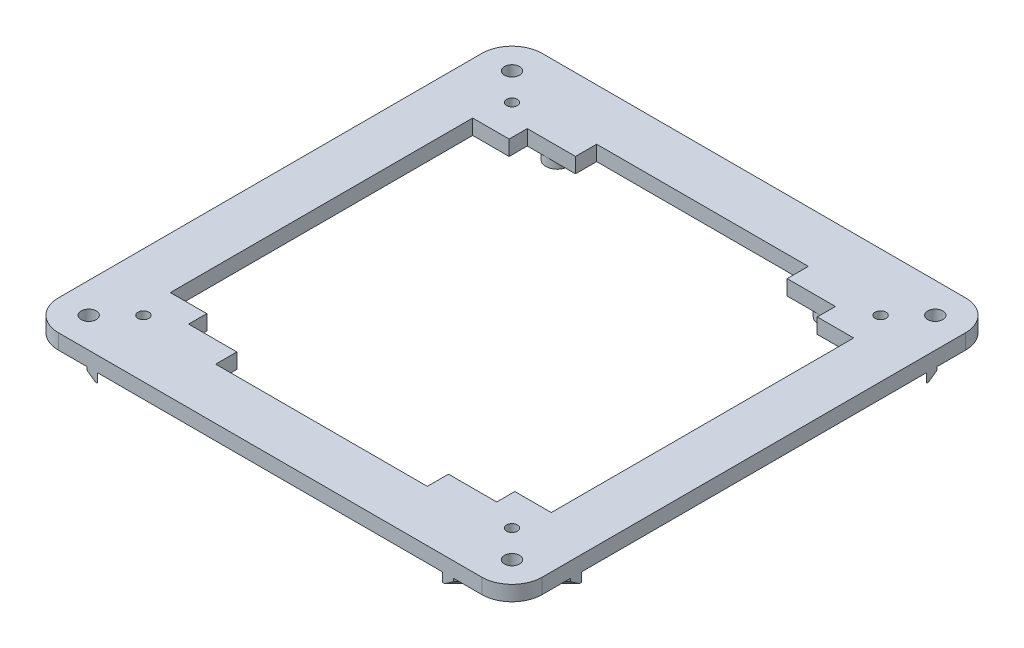
from build123d import *

# Parameters (mm, degrees)
SKETCH1_W           = 160.02
SKETCH1_H           = 127
BOSS_EXTRUDE2_DEPTH = 6.35
SKETCH2_R           = 3.175
CUT_EXTRUDE1_DEPTH  = 7.35
SKETCH8_R           = 2.286
CUT_EXTRUDE4_DEPTH  = 7.35
SKETCH10_R          = 4.826
SKETCH10_R_2        = 2.286
BOSS_EXTRUDE3_DEPTH = 3.81
BOSS_EXTRUDE4_DEPTH = 3.81
CHAMFER1_SIZE       = 2.54
CUT_EXTRUDE5_DEPTH  = 11.16


with BuildPart() as part:
    # Sketch1 → Boss-Extrude2 (new body)
    with BuildSketch(Plane(origin=(0, 0, 0), x_dir=(1, 0, 0), z_dir=(0, 1, 0))):
        with BuildLine():
            Line((0, 0), (0, 25.4))
            ThreePointArc((0, 25.4), (3.719743879, 34.380256121), (12.7, 38.1))
            Line((12.7, 38.1), (190.5, 38.1))
            ThreePointArc((190.5, 38.1), (199.480256121, 34.380256121), (203.2, 25.4))
            Line((203.2, 25.4), (203.2, -152.4))
            ThreePointArc((203.2, -152.4), (199.480256121, -161.380256121), (190.5, -165.1))
            Line((190.5, -165.1), (12.7, -165.1))
            ThreePointArc((12.7, -165.1), (3.719743879, -161.380256121), (0, -152.4))
            Line((0, -152.4), (0, -127))
            Line((0, -127), (0, 0))
        make_face()
        with Locations((101.6, -63.5)):
            Rectangle(SKETCH1_W, SKETCH1_H, mode=Mode.SUBTRACT)
    extrude(amount=BOSS_EXTRUDE2_DEPTH)

    # Sketch2 → Cut-Extrude1 (cut, through all)
    with BuildSketch(Plane(origin=(0, 6.35, 0), x_dir=(1, 0, 0), z_dir=(0, 1, 0))):
        with Locations((12.7, 25.4)):
            Circle(SKETCH2_R)
        with Locations((190.5, 25.4)):
            Circle(SKETCH2_R)
        with Locations((190.5, -152.4)):
            Circle(SKETCH2_R)
        with Locations((12.7, -152.4)):
            Circle(SKETCH2_R)
    extrude(amount=-CUT_EXTRUDE1_DEPTH, mode=Mode.SUBTRACT)

    # Sketch8 → Cut-Extrude4 (cut, through all)
    with BuildSketch(Plane(origin=(0, 0, 0), x_dir=(-1, 0, 0), z_dir=(0, -1, 0))):
        with Locations((-24.197781122, 13.902218878)):
            Circle(SKETCH8_R)
        with Locations((-24.197781122, -140.902218878)):
            Circle(SKETCH8_R)
        with Locations((-179.002218878, -140.902218878)):
            Circle(SKETCH8_R)
        with Locations((-179.002218878, 13.902218878)):
            Circle(SKETCH8_R)
    extrude(amount=-CUT_EXTRUDE4_DEPTH, mode=Mode.SUBTRACT)

    # Sketch10 → Boss-Extrude3 (add)
    with BuildSketch(Plane(origin=(0, 0, 0), x_dir=(-1, 0, 0), z_dir=(0, -1, 0))):
        with Locations((-44.45, 12.7)):
            Circle(SKETCH10_R)
        with Locations((-44.45, 12.7)):
            Circle(SKETCH10_R_2, mode=Mode.SUBTRACT)
        with Locations((-158.75, 12.7)):
            Circle(SKETCH10_R)
        with Locations((-158.75, 12.7)):
            Circle(SKETCH10_R_2, mode=Mode.SUBTRACT)
        with Locations((-158.75, -139.7)):
            Circle(SKETCH10_R)
        with Locations((-158.75, -139.7)):
            Circle(SKETCH10_R_2, mode=Mode.SUBTRACT)
        with Locations((-44.45, -139.7)):
            Circle(SKETCH10_R)
        with Locations((-44.45, -139.7)):
            Circle(SKETCH10_R_2, mode=Mode.SUBTRACT)
    extrude(amount=BOSS_EXTRUDE3_DEPTH)

    # Sketch11 → Boss-Extrude4 (add)
    with BuildSketch(Plane.XZ):
        with BuildLine():
            Line((174.07128, -38.1), (187.384850533, -24.786429467))
            ThreePointArc((187.384850533, -24.786429467), (187.552268433, -26.579620112), (188.668154157, -27.993253903))
            Line((188.668154157, -27.993253903), (178.561408061, -38.1))
            Line((178.561408061, -38.1), (174.07128, -38.1))
        make_face()
        with BuildLine():
            Line((203.2, -8.97128), (203.2, -13.461408061))
            Line((203.2, -13.461408061), (193.093253903, -23.568154157))
            ThreePointArc((193.093253903, -23.568154157), (191.679620112, -22.452268433), (189.886429467, -22.284850533))
            Line((189.886429467, -22.284850533), (203.2, -8.97128))
        make_face()
        with BuildLine():
            Line((10.106746097, -23.568154157), (0, -13.461408061))
            Line((0, -13.461408061), (0, -8.97128))
            Line((0, -8.97128), (13.313570533, -22.284850533))
            ThreePointArc((13.313570533, -22.284850533), (11.520379888, -22.452268433), (10.106746097, -23.568154157))
        make_face()
        with BuildLine():
            Line((15.815149467, -24.786429467), (29.12872, -38.1))
            Line((29.12872, -38.1), (24.638591939, -38.1))
            Line((24.638591939, -38.1), (14.531845843, -27.993253903))
            ThreePointArc((14.531845843, -27.993253903), (15.647731567, -26.579620112), (15.815149467, -24.786429467))
        make_face()
        with BuildLine():
            Line((14.531845843, 154.993253903), (24.638591939, 165.1))
            Line((24.638591939, 165.1), (29.12872, 165.1))
            Line((29.12872, 165.1), (15.815149467, 151.786429467))
            ThreePointArc((15.815149467, 151.786429467), (15.647731567, 153.579620112), (14.531845843, 154.993253903))
        make_face()
        with BuildLine():
            Line((13.313570533, 149.284850533), (0, 135.97128))
            Line((0, 135.97128), (0, 140.461408061))
            Line((0, 140.461408061), (10.106746097, 150.568154157))
            ThreePointArc((10.106746097, 150.568154157), (11.520379888, 149.452268433), (13.313570533, 149.284850533))
        make_face()
        with BuildLine():
            Line((193.093253903, 150.568154157), (203.2, 140.461408061))
            Line((203.2, 140.461408061), (203.2, 135.97128))
            Line((203.2, 135.97128), (189.886429467, 149.284850533))
            ThreePointArc((189.886429467, 149.284850533), (191.679620112, 149.452268433), (193.093253903, 150.568154157))
        make_face()
        with BuildLine():
            Line((187.384850533, 151.786429467), (174.07128, 165.1))
            Line((174.07128, 165.1), (178.561408061, 165.1))
            Line((178.561408061, 165.1), (188.668154157, 154.993253903))
            ThreePointArc((188.668154157, 154.993253903), (187.552268433, 153.579620112), (187.384850533, 151.786429467))
        make_face()
    extrude(amount=BOSS_EXTRUDE4_DEPTH)

    # Chamfer1
    chamfer1_edges = [part.edges().sort_by_distance(p)[0] for p in [
        (183.614781109, -3.81, -33.046626952),
        (198.146626952, -3.81, -18.514781109),
        (5.053373048, -3.81, -18.514781109),
        (19.585218891, -3.81, -33.046626952),
        (19.585218891, -3.81, 160.046626952),
        (5.053373048, -3.81, 145.514781109),
        (198.146626952, -3.81, 145.514781109),
        (183.614781109, -3.81, 160.046626952),
    ]]
    chamfer(chamfer1_edges, length=CHAMFER1_SIZE)

    # Sketch9 → Cut-Extrude5 (cut, through all)
    with BuildSketch(Plane(origin=(0, 6.35, 0), x_dir=(1, 0, 0), z_dir=(0, 1, 0))):
        Polygon((36.897781122, 0), (166.302218878, 0), (166.302218878, 7.62), (146.05, 7.62), (146.05, 16.51), (57.15, 16.51), (57.15, 7.62), (36.897781122, 7.62), align=None)
        Polygon((166.302218878, -127), (36.897781122, -127), (36.897781122, -134.62), (57.15, -134.62), (57.15, -143.51), (146.05, -143.51), (146.05, -134.62), (166.302218878, -134.62), align=None)
    extrude(amount=-CUT_EXTRUDE5_DEPTH, mode=Mode.SUBTRACT)


solid = part.part
